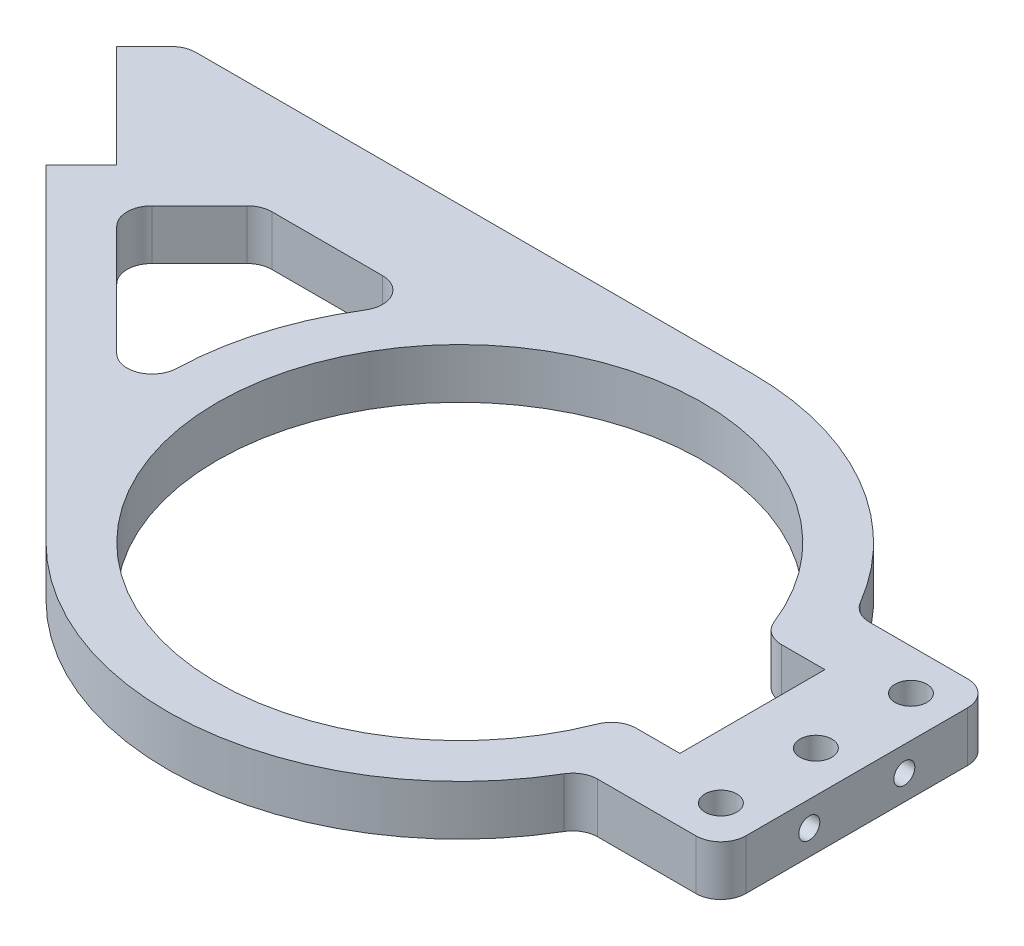
from build123d import *

# Parameters (mm, degrees)
BOSS_EXTRUDE1_DEPTH             = 5
M5X0_8_TAPPED_HOLE1_D           = 4.2
M5X0_8_TAPPED_HOLE1_DEPTH       = 40
M5X0_8_TAPPED_HOLE1_CSINK_D     = 5.05
M5X0_8_TAPPED_HOLE1_CSINK_ANGLE = 90
M5X0_8_TAPPED_HOLE1_TIP         = 1.2618073
M5X0_8_TAPPED_HOLE2_D           = 4.2
M5X0_8_TAPPED_HOLE2_DEPTH       = 20.875
M5X0_8_TAPPED_HOLE2_CSINK_D     = 5.05
M5X0_8_TAPPED_HOLE2_CSINK_ANGLE = 90
F_1_4_0_25_DIAMETER_HOLE1_D     = 6.35
FILLET1_R                       = 5


with BuildPart() as part:
    # Sketch1 → Boss-Extrude1 (new body, symmetric)
    with BuildSketch(Plane(origin=(0, 0, 0), x_dir=(1, 0, 0), z_dir=(0, 1, 0))):
        with BuildLine():
            Line((-120.190475132, 51.601117357), (-99.684378478, 31.095020703))
            Line((-99.684378478, 31.095020703), (-106.75544629, 24.023952891))
            Line((-106.75544629, 24.023952891), (-41.365746699, -41.365746699))
            ThreePointArc((-41.365746699, -41.365746699), (8.808484383, -57.833040754), (51.805109545, -27.175))
            Line((51.805109545, -27.175), (79.375, -27.175))
            Line((79.375, -27.175), (79.375, 27.175))
            Line((79.375, 27.175), (51.805109545, 27.175))
            ThreePointArc((51.805109545, 27.175), (30.269724974, 50.059901618), (0, 58.5))
            Line((0, 58.5), (-113.291592489, 58.5))
            Line((-113.291592489, 58.5), (-120.190475132, 51.601117357))
        make_face()
        with BuildLine():
            Line((58.5, -14.5), (58.5, 14.5))
            Line((58.5, 14.5), (46.281745862, 14.5))
            ThreePointArc((46.281745862, 14.5), (-48.5, 0), (46.281745862, -14.5))
            Line((46.281745862, -14.5), (58.5, -14.5))
        make_face(mode=Mode.SUBTRACT)
        with BuildLine():
            Line((-92.613310666, 24.023952891), (-57.4247459, -11.164611875))
            ThreePointArc((-57.4247459, -11.164611875), (-56.48621622, 15.217009469), (-44.045431091, 38.5))
            Line((-44.045431091, 38.5), (-78.137263557, 38.5))
            Line((-78.137263557, 38.5), (-92.613310666, 24.023952891))
        make_face(mode=Mode.SUBTRACT)
    extrude(amount=BOSS_EXTRUDE1_DEPTH, both=True)

    # M5x0.8 Tapped Hole1
    with Locations(Plane(origin=(-34.294678888, 0, 34.294678888), x_dir=(0.707106781, 0, 0.707106781), z_dir=(-0.707106781, 0, 0.707106781))):
        with Locations((-116.475, 0), (-97.475, 0)):
            CounterSinkHole(M5X0_8_TAPPED_HOLE1_D / 2, M5X0_8_TAPPED_HOLE1_CSINK_D / 2, depth=M5X0_8_TAPPED_HOLE1_DEPTH, counter_sink_angle=M5X0_8_TAPPED_HOLE1_CSINK_ANGLE)
            with Locations((0, 0, -(M5X0_8_TAPPED_HOLE1_DEPTH + M5X0_8_TAPPED_HOLE1_TIP / 2))):  # 118° drill point
                Cone(0, M5X0_8_TAPPED_HOLE1_D / 2, M5X0_8_TAPPED_HOLE1_TIP, mode=Mode.SUBTRACT)

    # M5x0.8 Tapped Hole2
    with Locations(Plane.ZY.offset(-58.5)):
        with Locations((-9.5, 0), (9.5, 0)):
            CounterSinkHole(M5X0_8_TAPPED_HOLE2_D / 2, M5X0_8_TAPPED_HOLE2_CSINK_D / 2, depth=M5X0_8_TAPPED_HOLE2_DEPTH, counter_sink_angle=M5X0_8_TAPPED_HOLE2_CSINK_ANGLE)

    # 1/4 (0.25) Diameter Hole1 (through all)
    with Locations(Plane(origin=(0, 5, 0), x_dir=(1, 0, 0), z_dir=(0, 1, 0))):
        with Locations((71.2, 19), (71.2, 0), (71.2, -19)):
            Hole(F_1_4_0_25_DIAMETER_HOLE1_D / 2)

    # Fillet1
    fillet1_edges = [part.edges().sort_by_distance(p)[0] for p in [
        (-113.291592489, 0, -58.5),
        (51.805109545, 0, -27.175),
        (79.375, 0, -27.175),
        (79.375, 0, 27.175),
        (51.805109545, 0, 27.175),
        (46.281745862, 0, 14.5),
        (46.281745862, 0, -14.5),
        (-92.613310666, 0, -24.023952891),
        (-78.137263557, 0, -38.5),
        (-44.045431091, 0, -38.5),
        (-57.4247459, 0, 11.164611875),
    ]]
    fillet(fillet1_edges, radius=FILLET1_R)


solid = part.part
